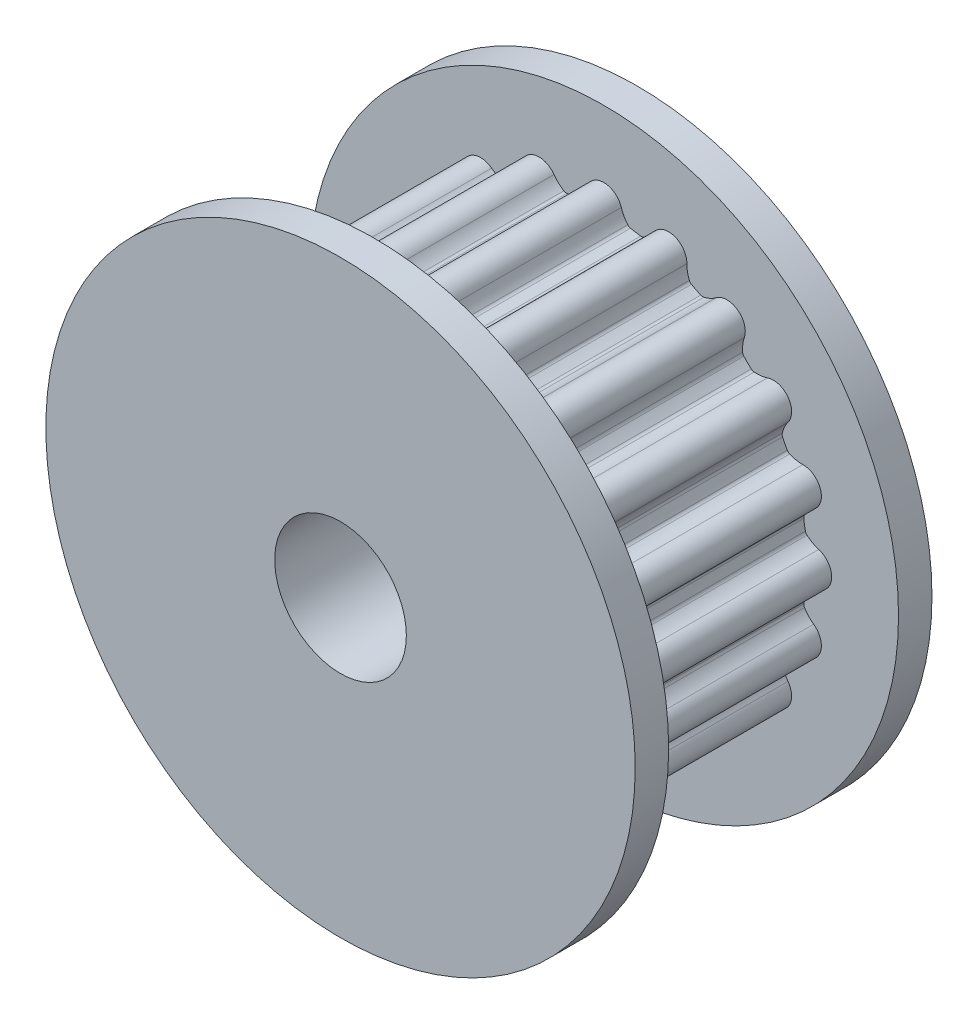
from build123d import *

# Parameters (mm, degrees)
SKETCH1_R           = 8.9535
SKETCH1_R_2         = 2
BOSS_EXTRUDE1_DEPTH = 1.016
SKETCH2_R           = 2
BOSS_EXTRUDE2_DEPTH = 6.985
SKETCH3_R           = 8.9535
SKETCH3_R_2         = 2
BOSS_EXTRUDE3_DEPTH = 1.016


with BuildPart() as part:
    # Sketch1 → Boss-Extrude1 (new body)
    with BuildSketch(Plane.XY):
        Circle(SKETCH1_R)
        Circle(SKETCH1_R_2, mode=Mode.SUBTRACT)
    extrude(amount=BOSS_EXTRUDE1_DEPTH)

    # Sketch2 → Boss-Extrude2 (add)
    with BuildSketch(Plane.XY.offset(1.016)):
        with BuildLine():
            ThreePointArc((0.530336211, 6.529808553), (0.329561064, 6.812756236), (0, 6.921197724))
            ThreePointArc((0, 6.921197724), (-0.329561064, 6.812756236), (-0.530336211, 6.529808553))
            ThreePointArc((-0.530336211, 6.529808553), (-0.610465335, 6.341260842), (-0.727337126, 6.172999438))
            ThreePointArc((-0.727337126, 6.172999438), (-0.764621841, 6.141713349), (-0.809960974, 6.124012151))
            ThreePointArc((-0.809960974, 6.124012151), (-0.965388015, 6.095220039), (-1.122105166, 6.074573368))
            ThreePointArc((-1.122105166, 6.074573368), (-1.170695215, 6.077397645), (-1.215823019, 6.095630874))
            ThreePointArc((-1.215823019, 6.095630874), (-1.378970331, 6.219541609), (-1.513442104, 6.374099876))
            ThreePointArc((-1.513442104, 6.374099876), (-1.791826258, 6.581156182), (-2.138767718, 6.582450196))
            ThreePointArc((-2.138767718, 6.582450196), (-2.418688653, 6.377476243), (-2.522201522, 6.046334072))
            ThreePointArc((-2.522201522, 6.046334072), (-2.540144401, 5.842253283), (-2.599300446, 5.646111808))
            ThreePointArc((-2.599300446, 5.646111808), (-2.625092384, 5.604835358), (-2.662742491, 5.573989956))
            ThreePointArc((-2.662742491, 5.573989956), (-2.801665139, 5.498577434), (-2.944331835, 5.430513019))
            ThreePointArc((-2.944331835, 5.430513019), (-2.991416466, 5.418183916), (-3.039969936, 5.421579488))
            ThreePointArc((-3.039969936, 5.421579488), (-3.233422773, 5.489010308), (-3.40907416, 5.594449893))
            ThreePointArc((-3.40907416, 5.594449893), (-3.737817142, 5.705346707), (-4.06817795, 5.59936658))
            ThreePointArc((-4.06817795, 5.59936658), (-4.271058145, 5.31792444), (-4.267176175, 4.971002286))
            ThreePointArc((-4.267176175, 4.971002286), (-4.221176435, 4.771365266), (-4.216826128, 4.566543415))
            ThreePointArc((-4.216826128, 4.566543415), (-4.228600594, 4.519317032), (-4.25487622, 4.478346789))
            ThreePointArc((-4.25487622, 4.478346789), (-4.363695758, 4.363695758), (-4.478346789, 4.25487622))
            ThreePointArc((-4.478346789, 4.25487622), (-4.519317032, 4.228600594), (-4.566543415, 4.216826128))
            ThreePointArc((-4.566543415, 4.216826128), (-4.771365266, 4.221176435), (-4.971002286, 4.267176175))
            ThreePointArc((-4.971002286, 4.267176175), (-5.31792444, 4.271058145), (-5.59936658, 4.06817795))
            ThreePointArc((-5.59936658, 4.06817795), (-5.705346707, 3.737817142), (-5.594449893, 3.40907416))
            ThreePointArc((-5.594449893, 3.40907416), (-5.489010308, 3.233422773), (-5.421579488, 3.039969936))
            ThreePointArc((-5.421579488, 3.039969936), (-5.418183916, 2.991416466), (-5.430513019, 2.944331835))
            ThreePointArc((-5.430513019, 2.944331835), (-5.498577434, 2.801665139), (-5.573989956, 2.662742491))
            ThreePointArc((-5.573989956, 2.662742491), (-5.604835358, 2.625092384), (-5.646111808, 2.599300446))
            ThreePointArc((-5.646111808, 2.599300446), (-5.842253283, 2.540144401), (-6.046334072, 2.522201522))
            ThreePointArc((-6.046334072, 2.522201522), (-6.377476243, 2.418688653), (-6.582450196, 2.138767718))
            ThreePointArc((-6.582450196, 2.138767718), (-6.581156182, 1.791826258), (-6.374099876, 1.513442104))
            ThreePointArc((-6.374099876, 1.513442104), (-6.219541609, 1.378970331), (-6.095630874, 1.215823019))
            ThreePointArc((-6.095630874, 1.215823019), (-6.077397645, 1.170695215), (-6.074573368, 1.122105166))
            ThreePointArc((-6.074573368, 1.122105166), (-6.095220039, 0.965388015), (-6.124012151, 0.809960974))
            ThreePointArc((-6.124012151, 0.809960974), (-6.141713349, 0.764621841), (-6.172999438, 0.727337126))
            ThreePointArc((-6.172999438, 0.727337126), (-6.341260842, 0.610465335), (-6.529808553, 0.530336211))
            ThreePointArc((-6.529808553, 0.530336211), (-6.812756236, 0.329561064), (-6.921197724, 0))
            ThreePointArc((-6.921197724, 0), (-6.812756236, -0.329561064), (-6.529808553, -0.530336211))
            ThreePointArc((-6.529808553, -0.530336211), (-6.341260842, -0.610465335), (-6.172999438, -0.727337126))
            ThreePointArc((-6.172999438, -0.727337126), (-6.141713349, -0.764621841), (-6.124012151, -0.809960974))
            ThreePointArc((-6.124012151, -0.809960974), (-6.095220039, -0.965388015), (-6.074573368, -1.122105166))
            ThreePointArc((-6.074573368, -1.122105166), (-6.077397645, -1.170695215), (-6.095630874, -1.215823019))
            ThreePointArc((-6.095630874, -1.215823019), (-6.219541609, -1.378970331), (-6.374099876, -1.513442104))
            ThreePointArc((-6.374099876, -1.513442104), (-6.581156182, -1.791826258), (-6.582450196, -2.138767718))
            ThreePointArc((-6.582450196, -2.138767718), (-6.377476243, -2.418688653), (-6.046334072, -2.522201522))
            ThreePointArc((-6.046334072, -2.522201522), (-5.842253283, -2.540144401), (-5.646111808, -2.599300446))
            ThreePointArc((-5.646111808, -2.599300446), (-5.604835358, -2.625092384), (-5.573989956, -2.662742491))
            ThreePointArc((-5.573989956, -2.662742491), (-5.498577434, -2.801665139), (-5.430513019, -2.944331835))
            ThreePointArc((-5.430513019, -2.944331835), (-5.418183916, -2.991416466), (-5.421579488, -3.039969936))
            ThreePointArc((-5.421579488, -3.039969936), (-5.489010308, -3.233422773), (-5.594449893, -3.40907416))
            ThreePointArc((-5.594449893, -3.40907416), (-5.705346707, -3.737817142), (-5.59936658, -4.06817795))
            ThreePointArc((-5.59936658, -4.06817795), (-5.31792444, -4.271058145), (-4.971002286, -4.267176175))
            ThreePointArc((-4.971002286, -4.267176175), (-4.771365266, -4.221176435), (-4.566543415, -4.216826128))
            ThreePointArc((-4.566543415, -4.216826128), (-4.519317032, -4.228600594), (-4.478346789, -4.25487622))
            ThreePointArc((-4.478346789, -4.25487622), (-4.363695758, -4.363695758), (-4.25487622, -4.478346789))
            ThreePointArc((-4.25487622, -4.478346789), (-4.228600594, -4.519317032), (-4.216826128, -4.566543415))
            ThreePointArc((-4.216826128, -4.566543415), (-4.221176435, -4.771365266), (-4.267176175, -4.971002286))
            ThreePointArc((-4.267176175, -4.971002286), (-4.271058145, -5.31792444), (-4.06817795, -5.59936658))
            ThreePointArc((-4.06817795, -5.59936658), (-3.737817142, -5.705346707), (-3.40907416, -5.594449893))
            ThreePointArc((-3.40907416, -5.594449893), (-3.233422773, -5.489010308), (-3.039969936, -5.421579488))
            ThreePointArc((-3.039969936, -5.421579488), (-2.991416466, -5.418183916), (-2.944331835, -5.430513019))
            ThreePointArc((-2.944331835, -5.430513019), (-2.801665139, -5.498577434), (-2.662742491, -5.573989956))
            ThreePointArc((-2.662742491, -5.573989956), (-2.625092384, -5.604835358), (-2.599300446, -5.646111808))
            ThreePointArc((-2.599300446, -5.646111808), (-2.540144401, -5.842253283), (-2.522201522, -6.046334072))
            ThreePointArc((-2.522201522, -6.046334072), (-2.418688653, -6.377476243), (-2.138767718, -6.582450196))
            ThreePointArc((-2.138767718, -6.582450196), (-1.791826258, -6.581156182), (-1.513442104, -6.374099876))
            ThreePointArc((-1.513442104, -6.374099876), (-1.378970331, -6.219541609), (-1.215823019, -6.095630874))
            ThreePointArc((-1.215823019, -6.095630874), (-1.170695215, -6.077397645), (-1.122105166, -6.074573368))
            ThreePointArc((-1.122105166, -6.074573368), (-0.965388015, -6.095220039), (-0.809960974, -6.124012151))
            ThreePointArc((-0.809960974, -6.124012151), (-0.764621841, -6.141713349), (-0.727337126, -6.172999438))
            ThreePointArc((-0.727337126, -6.172999438), (-0.610465335, -6.341260842), (-0.530336211, -6.529808553))
            ThreePointArc((-0.530336211, -6.529808553), (-0.329561064, -6.812756236), (0, -6.921197724))
            ThreePointArc((0, -6.921197724), (0.329561064, -6.812756236), (0.530336211, -6.529808553))
            ThreePointArc((0.530336211, -6.529808553), (0.610465335, -6.341260842), (0.727337126, -6.172999438))
            ThreePointArc((0.727337126, -6.172999438), (0.764621841, -6.141713349), (0.809960974, -6.124012151))
            ThreePointArc((0.809960974, -6.124012151), (0.965388015, -6.095220039), (1.122105166, -6.074573368))
            ThreePointArc((1.122105166, -6.074573368), (1.170695215, -6.077397645), (1.215823019, -6.095630874))
            ThreePointArc((1.215823019, -6.095630874), (1.378970331, -6.219541609), (1.513442104, -6.374099876))
            ThreePointArc((1.513442104, -6.374099876), (1.791826258, -6.581156182), (2.138767718, -6.582450196))
            ThreePointArc((2.138767718, -6.582450196), (2.418688653, -6.377476243), (2.522201522, -6.046334072))
            ThreePointArc((2.522201522, -6.046334072), (2.540144401, -5.842253283), (2.599300446, -5.646111808))
            ThreePointArc((2.599300446, -5.646111808), (2.625092384, -5.604835358), (2.662742491, -5.573989956))
            ThreePointArc((2.662742491, -5.573989956), (2.801665139, -5.498577434), (2.944331835, -5.430513019))
            ThreePointArc((2.944331835, -5.430513019), (2.991416466, -5.418183916), (3.039969936, -5.421579488))
            ThreePointArc((3.039969936, -5.421579488), (3.233422773, -5.489010308), (3.40907416, -5.594449893))
            ThreePointArc((3.40907416, -5.594449893), (3.737817142, -5.705346707), (4.06817795, -5.59936658))
            ThreePointArc((4.06817795, -5.59936658), (4.271058145, -5.31792444), (4.267176175, -4.971002286))
            ThreePointArc((4.267176175, -4.971002286), (4.221176435, -4.771365266), (4.216826128, -4.566543415))
            ThreePointArc((4.216826128, -4.566543415), (4.228600594, -4.519317032), (4.25487622, -4.478346789))
            ThreePointArc((4.25487622, -4.478346789), (4.363695758, -4.363695758), (4.478346789, -4.25487622))
            ThreePointArc((4.478346789, -4.25487622), (4.519317032, -4.228600594), (4.566543415, -4.216826128))
            ThreePointArc((4.566543415, -4.216826128), (4.771365266, -4.221176435), (4.971002286, -4.267176175))
            ThreePointArc((4.971002286, -4.267176175), (5.31792444, -4.271058145), (5.59936658, -4.06817795))
            ThreePointArc((5.59936658, -4.06817795), (5.705346707, -3.737817142), (5.594449893, -3.40907416))
            ThreePointArc((5.594449893, -3.40907416), (5.489010308, -3.233422773), (5.421579488, -3.039969936))
            ThreePointArc((5.421579488, -3.039969936), (5.418183916, -2.991416466), (5.430513019, -2.944331835))
            ThreePointArc((5.430513019, -2.944331835), (5.498577434, -2.801665139), (5.573989956, -2.662742491))
            ThreePointArc((5.573989956, -2.662742491), (5.604835358, -2.625092384), (5.646111808, -2.599300446))
            ThreePointArc((5.646111808, -2.599300446), (5.842253283, -2.540144401), (6.046334072, -2.522201522))
            ThreePointArc((6.046334072, -2.522201522), (6.377476243, -2.418688653), (6.582450196, -2.138767718))
            ThreePointArc((6.582450196, -2.138767718), (6.581156182, -1.791826258), (6.374099876, -1.513442104))
            ThreePointArc((6.374099876, -1.513442104), (6.219541609, -1.378970331), (6.095630874, -1.215823019))
            ThreePointArc((6.095630874, -1.215823019), (6.077397645, -1.170695215), (6.074573368, -1.122105166))
            ThreePointArc((6.074573368, -1.122105166), (6.095220039, -0.965388015), (6.124012151, -0.809960974))
            ThreePointArc((6.124012151, -0.809960974), (6.141713349, -0.764621841), (6.172999438, -0.727337126))
            ThreePointArc((6.172999438, -0.727337126), (6.341260842, -0.610465335), (6.529808553, -0.530336211))
            ThreePointArc((6.529808553, -0.530336211), (6.812756236, -0.329561064), (6.921197724, 0))
            ThreePointArc((6.921197724, 0), (6.812756236, 0.329561064), (6.529808553, 0.530336211))
            ThreePointArc((6.529808553, 0.530336211), (6.341260842, 0.610465335), (6.172999438, 0.727337126))
            ThreePointArc((6.172999438, 0.727337126), (6.141713349, 0.764621841), (6.124012151, 0.809960974))
            ThreePointArc((6.124012151, 0.809960974), (6.095220039, 0.965388015), (6.074573368, 1.122105166))
            ThreePointArc((6.074573368, 1.122105166), (6.077397645, 1.170695215), (6.095630874, 1.215823019))
            ThreePointArc((6.095630874, 1.215823019), (6.219541609, 1.378970331), (6.374099876, 1.513442104))
            ThreePointArc((6.374099876, 1.513442104), (6.581156182, 1.791826258), (6.582450196, 2.138767718))
            ThreePointArc((6.582450196, 2.138767718), (6.377476243, 2.418688653), (6.046334072, 2.522201522))
            ThreePointArc((6.046334072, 2.522201522), (5.842253283, 2.540144401), (5.646111808, 2.599300446))
            ThreePointArc((5.646111808, 2.599300446), (5.604835358, 2.625092384), (5.573989956, 2.662742491))
            ThreePointArc((5.573989956, 2.662742491), (5.498577434, 2.801665139), (5.430513019, 2.944331835))
            ThreePointArc((5.430513019, 2.944331835), (5.418183916, 2.991416466), (5.421579488, 3.039969936))
            ThreePointArc((5.421579488, 3.039969936), (5.489010308, 3.233422773), (5.594449893, 3.40907416))
            ThreePointArc((5.594449893, 3.40907416), (5.705346707, 3.737817142), (5.59936658, 4.06817795))
            ThreePointArc((5.59936658, 4.06817795), (5.31792444, 4.271058145), (4.971002286, 4.267176175))
            ThreePointArc((4.971002286, 4.267176175), (4.771365266, 4.221176435), (4.566543415, 4.216826128))
            ThreePointArc((4.566543415, 4.216826128), (4.519317032, 4.228600594), (4.478346789, 4.25487622))
            ThreePointArc((4.478346789, 4.25487622), (4.363695758, 4.363695758), (4.25487622, 4.478346789))
            ThreePointArc((4.25487622, 4.478346789), (4.228600594, 4.519317032), (4.216826128, 4.566543415))
            ThreePointArc((4.216826128, 4.566543415), (4.221176435, 4.771365266), (4.267176175, 4.971002286))
            ThreePointArc((4.267176175, 4.971002286), (4.271058145, 5.31792444), (4.06817795, 5.59936658))
            ThreePointArc((4.06817795, 5.59936658), (3.737817142, 5.705346707), (3.40907416, 5.594449893))
            ThreePointArc((3.40907416, 5.594449893), (3.233422773, 5.489010308), (3.039969936, 5.421579488))
            ThreePointArc((3.039969936, 5.421579488), (2.991416466, 5.418183916), (2.944331835, 5.430513019))
            ThreePointArc((2.944331835, 5.430513019), (2.801665139, 5.498577434), (2.662742491, 5.573989956))
            ThreePointArc((2.662742491, 5.573989956), (2.625092384, 5.604835358), (2.599300446, 5.646111808))
            ThreePointArc((2.599300446, 5.646111808), (2.540144401, 5.842253283), (2.522201522, 6.046334072))
            ThreePointArc((2.522201522, 6.046334072), (2.418688653, 6.377476243), (2.138767718, 6.582450196))
            ThreePointArc((2.138767718, 6.582450196), (1.791826258, 6.581156182), (1.513442104, 6.374099876))
            ThreePointArc((1.513442104, 6.374099876), (1.378970331, 6.219541609), (1.215823019, 6.095630874))
            ThreePointArc((1.215823019, 6.095630874), (1.170695215, 6.077397645), (1.122105166, 6.074573368))
            ThreePointArc((1.122105166, 6.074573368), (0.965388015, 6.095220039), (0.809960974, 6.124012151))
            ThreePointArc((0.809960974, 6.124012151), (0.764621841, 6.141713349), (0.727337126, 6.172999438))
            ThreePointArc((0.727337126, 6.172999438), (0.610465335, 6.341260842), (0.530336211, 6.529808553))
        make_face()
        Circle(SKETCH2_R, mode=Mode.SUBTRACT)
    extrude(amount=BOSS_EXTRUDE2_DEPTH)

    # Sketch3 → Boss-Extrude3 (add)
    with BuildSketch(Plane.XY.offset(8.001)):
        Circle(SKETCH3_R)
        Circle(SKETCH3_R_2, mode=Mode.SUBTRACT)
    extrude(amount=BOSS_EXTRUDE3_DEPTH)


solid = part.part
